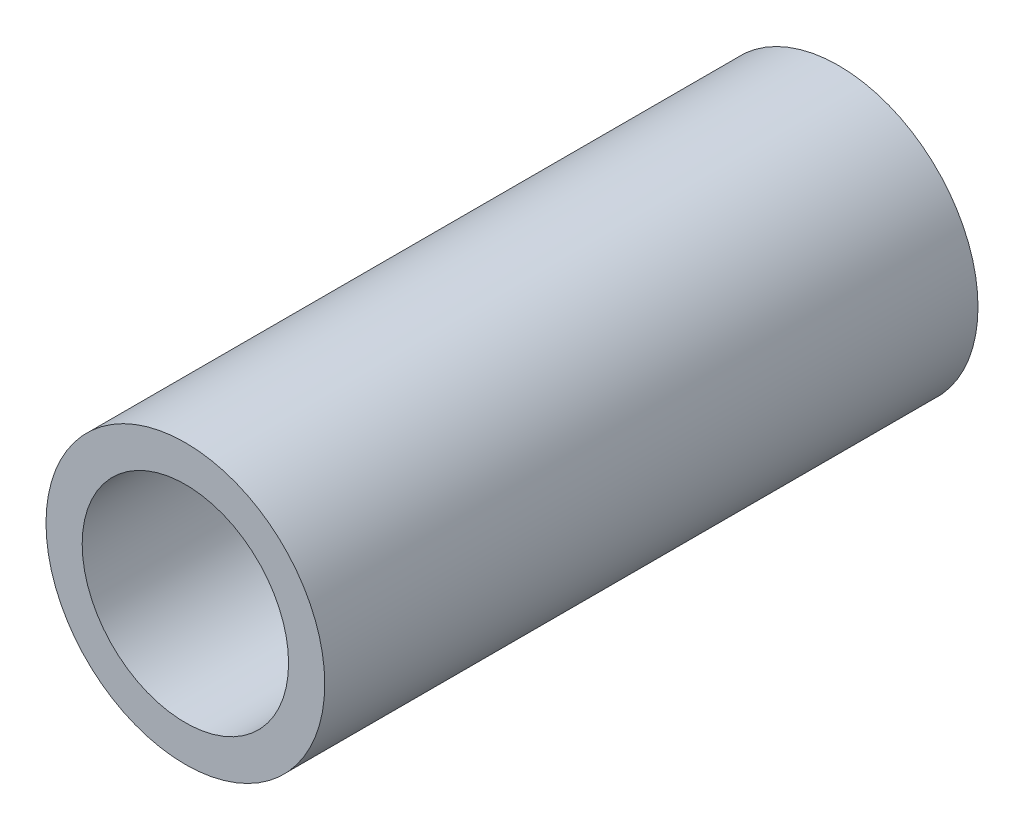
from build123d import *

# Parameters (mm, degrees)
SKETCH1_R           = 10.668
SKETCH1_R_2         = 7.8994
EXTRUDE_THIN1_DEPTH = 25


with BuildPart() as part:
    # Sketch1 → Extrude-Thin1 (new body, symmetric)
    with BuildSketch(Plane.XY):
        Circle(SKETCH1_R)
        Circle(SKETCH1_R_2, mode=Mode.SUBTRACT)
    extrude(amount=EXTRUDE_THIN1_DEPTH, both=True)


solid = part.part
